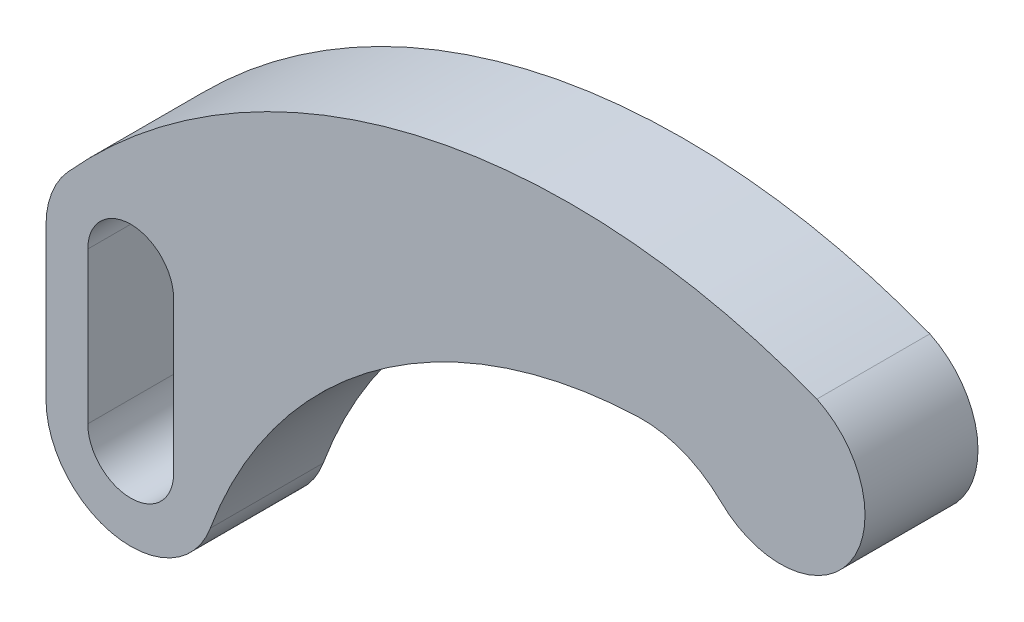
from build123d import *

# Parameters (mm, degrees)
BOSS_EXTRUDE1_DEPTH = 25.4


with BuildPart() as part:
    # Sketch2 → Boss-Extrude1 (new body)
    with BuildSketch(Plane.XY):
        with BuildLine():
            Line((-157.342145667, -6.429422494), (-157.342145667, -40.465422494))
            ThreePointArc((-157.342145667, -40.465422494), (-141.629836885, -59.2207502), (-120.41171865, -47.037547699))
            ThreePointArc((-120.41171865, -47.037547699), (-82.973266833, 2.473921311), (-24.309833539, 22.762460739))
            ThreePointArc((-24.309833539, 22.762460739), (-14.196167577, 21.07351252), (-5.57436841, 15.523434648))
            ThreePointArc((-5.57436841, 15.523434648), (23.363587608, 18.205213028), (15.981707982, 46.314021024))
            ThreePointArc((15.981707982, 46.314021024), (14.448779168, 46.900655432), (12.909621311, 47.470746453))
            ThreePointArc((12.909621311, 47.470746453), (-76.05269782, 52.166250257), (-152.440538162, 6.326967661))
            ThreePointArc((-152.440538162, 6.326967661), (-156.074572062, 0.403425483), (-157.342145667, -6.429422494))
        make_face()
        with BuildLine():
            Line((-147.944145667, -40.465422494), (-147.944145667, -6.429422494))
            ThreePointArc((-147.944145667, -6.429422494), (-138.292145667, 3.222577506), (-128.640145667, -6.429422494))
            Line((-128.640145667, -6.429422494), (-128.640145667, -40.465422494))
            ThreePointArc((-128.640145667, -40.465422494), (-138.292145667, -50.117422494), (-147.944145667, -40.465422494))
        make_face(mode=Mode.SUBTRACT)
    extrude(amount=BOSS_EXTRUDE1_DEPTH)


solid = part.part
